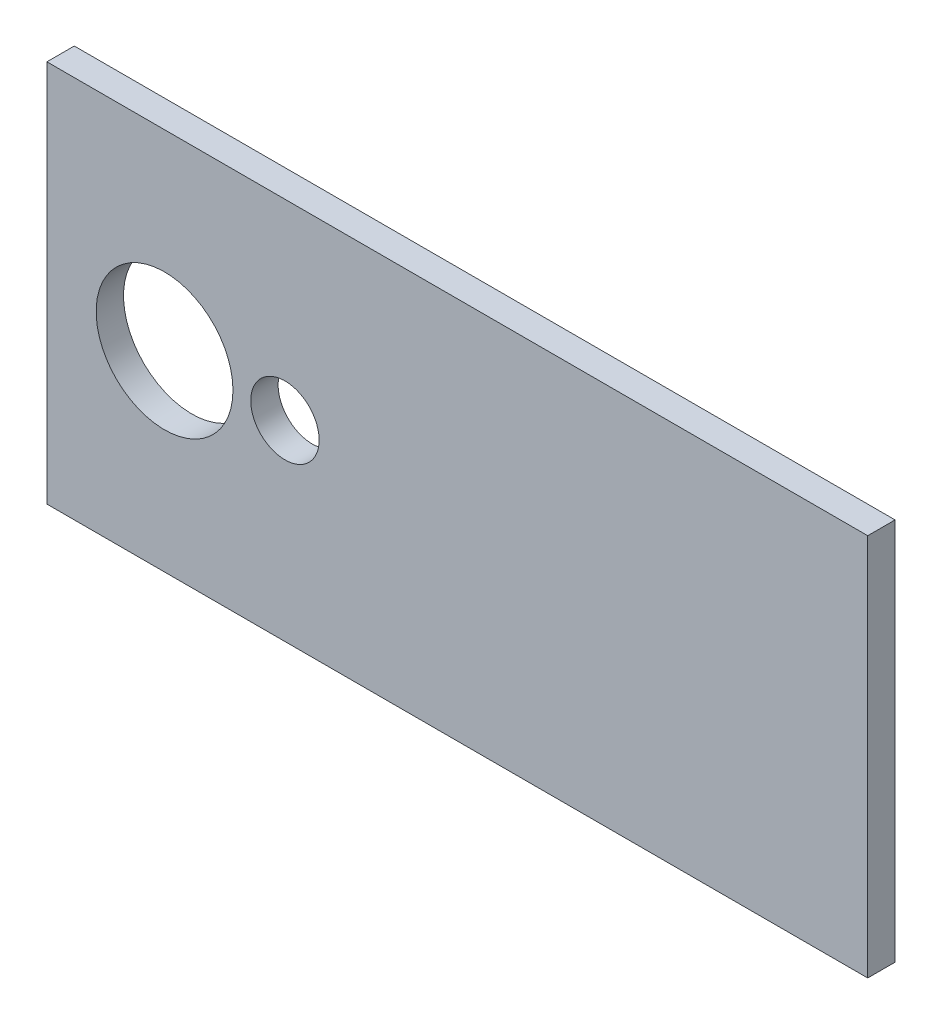
from build123d import *

# Parameters (mm, degrees)
SKETCH1_W           = 190.5
SKETCH1_H           = 88.9
SKETCH1_R           = 15.875
SKETCH1_R_2         = 7.9375
BOSS_EXTRUDE1_DEPTH = 3.175


with BuildPart() as part:
    # Sketch1 → Boss-Extrude1 (new body, symmetric)
    with BuildSketch(Plane.XY):
        Rectangle(SKETCH1_W, SKETCH1_H)
        with Locations((-67.945, 0)):
            Circle(SKETCH1_R, mode=Mode.SUBTRACT)
        with Locations((-40.005, 0)):
            Circle(SKETCH1_R_2, mode=Mode.SUBTRACT)
    extrude(amount=BOSS_EXTRUDE1_DEPTH, both=True)


solid = part.part
